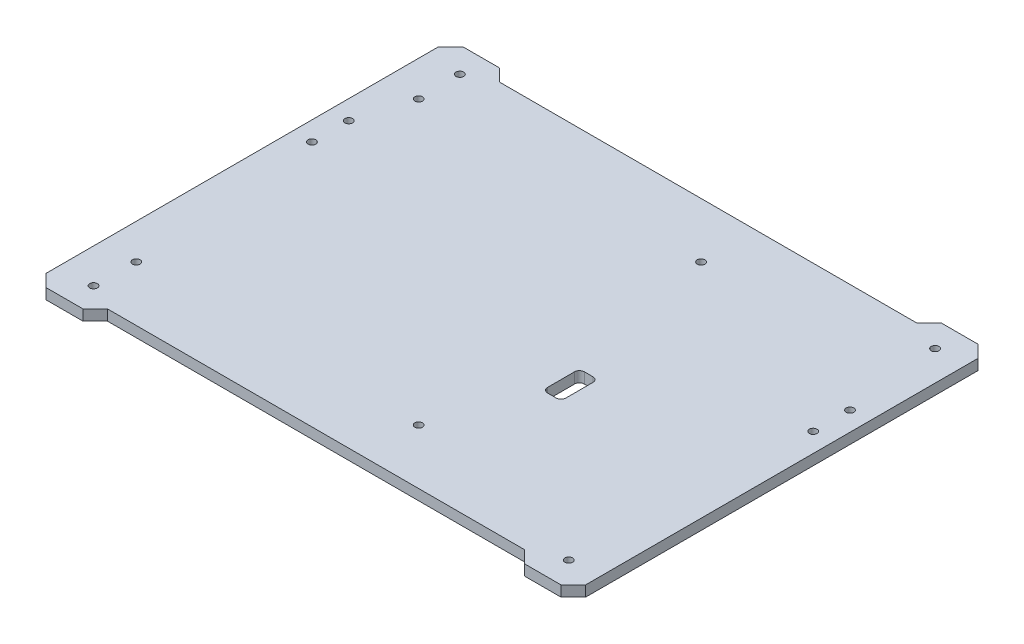
from build123d import *

# Parameters (mm, degrees)
SKETCH1_W                       = 279.4
SKETCH1_H                       = 215.9
BOSS_EXTRUDE1_DEPTH             = 5.5118
F_5_32_0_15625_DIAMETER_HOLE1_D = 3.96875
F_5_32_0_15625_DIAMETER_HOLE2_D = 3.96875
CUT_EXTRUDE2_DEPTH              = 6.5118
CHAMFER1_SIZE                   = 6.35
CUT_EXTRUDE3_DEPTH              = 6.5118


with BuildPart() as part:
    # Sketch1 → Boss-Extrude1 (new body)
    with BuildSketch(Plane(origin=(0, 0, 0), x_dir=(1, 0, 0), z_dir=(0, 1, 0))):
        with Locations((139.7, 107.95)):
            Rectangle(SKETCH1_W, SKETCH1_H)
    extrude(amount=BOSS_EXTRUDE1_DEPTH)

    # 5/32 (0.15625) Diameter Hole1 (through all)
    with Locations(Plane(origin=(0, 5.5118, 0), x_dir=(1, 0, 0), z_dir=(0, 1, 0))):
        with Locations((17.859375, 13.096875), (17.859375, 202.803125), (9.921875, 153.19375), (9.921875, 134.14375), (263.921875, 13.096875), (269.478125, 134.14375), (269.478125, 153.19375), (263.921875, 202.803125)):
            Hole(F_5_32_0_15625_DIAMETER_HOLE1_D / 2)

    # 5/32 (0.15625) Diameter Hole2 (through all)
    with Locations(Plane(origin=(0, 5.5118, 0), x_dir=(1, 0, 0), z_dir=(0, 1, 0))):
        with Locations((18.25625, 34.8361), (164.48405, 34.8361), (164.48405, 181.0639), (18.25625, 181.0639)):
            Hole(F_5_32_0_15625_DIAMETER_HOLE2_D / 2)

    # Sketch6 → Cut-Extrude2 (cut, through all)
    with BuildSketch(Plane(origin=(0, 5.5118, 0), x_dir=(1, 0, 0), z_dir=(0, 1, 0))):
        Polygon((247.65, 209.55), (254, 215.9), (25.4, 215.9), (31.75, 209.55), align=None)
        Polygon((25.4, 0), (254, 0), (247.65, 6.35), (31.75, 6.35), align=None)
    extrude(amount=-CUT_EXTRUDE2_DEPTH, mode=Mode.SUBTRACT)

    # Chamfer1
    chamfer1_edges = [part.edges().sort_by_distance(p)[0] for p in [
        (0, 2.7559, -215.9),
        (279.4, 2.7559, -215.9),
        (279.4, 2.7559, 0),
        (0, 2.7559, 0),
    ]]
    chamfer(chamfer1_edges, length=CHAMFER1_SIZE)

    # Sketch7 → Cut-Extrude3 (cut, through all)
    with BuildSketch(Plane(origin=(0, 5.5118, 0), x_dir=(1, 0, 0), z_dir=(0, 1, 0))):
        with BuildLine():
            Line((183.515, 101.6), (187.96, 101.6))
            ThreePointArc((187.96, 101.6), (189.756051224, 100.856051224), (190.5, 99.06))
            Line((190.5, 99.06), (190.5, 85.09))
            ThreePointArc((190.5, 85.09), (189.756051224, 83.293948776), (187.96, 82.55))
            Line((187.96, 82.55), (183.515, 82.55))
            ThreePointArc((183.515, 82.55), (181.718948776, 83.293948776), (180.975, 85.09))
            Line((180.975, 85.09), (180.975, 99.06))
            ThreePointArc((180.975, 99.06), (181.718948776, 100.856051224), (183.515, 101.6))
        make_face()
    extrude(amount=-CUT_EXTRUDE3_DEPTH, mode=Mode.SUBTRACT)


solid = part.part
